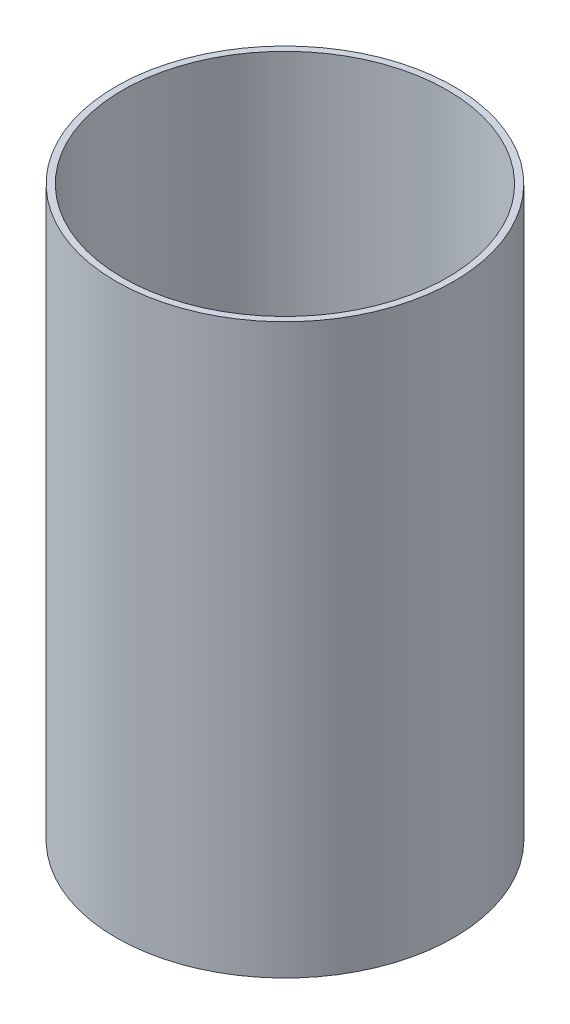
from build123d import *

# Parameters (mm, degrees)
SKETCH2_W = 1.524
SKETCH2_H = 133.35


with BuildPart() as part:
    # Sketch2 → Revolve1 (revolve)
    with BuildSketch(Plane.XY):
        with Locations((-38.862, -66.675)):
            Rectangle(SKETCH2_W, SKETCH2_H)
    revolve(axis=Axis((0, 55, 0), (0, -1, 0)))


solid = part.part
